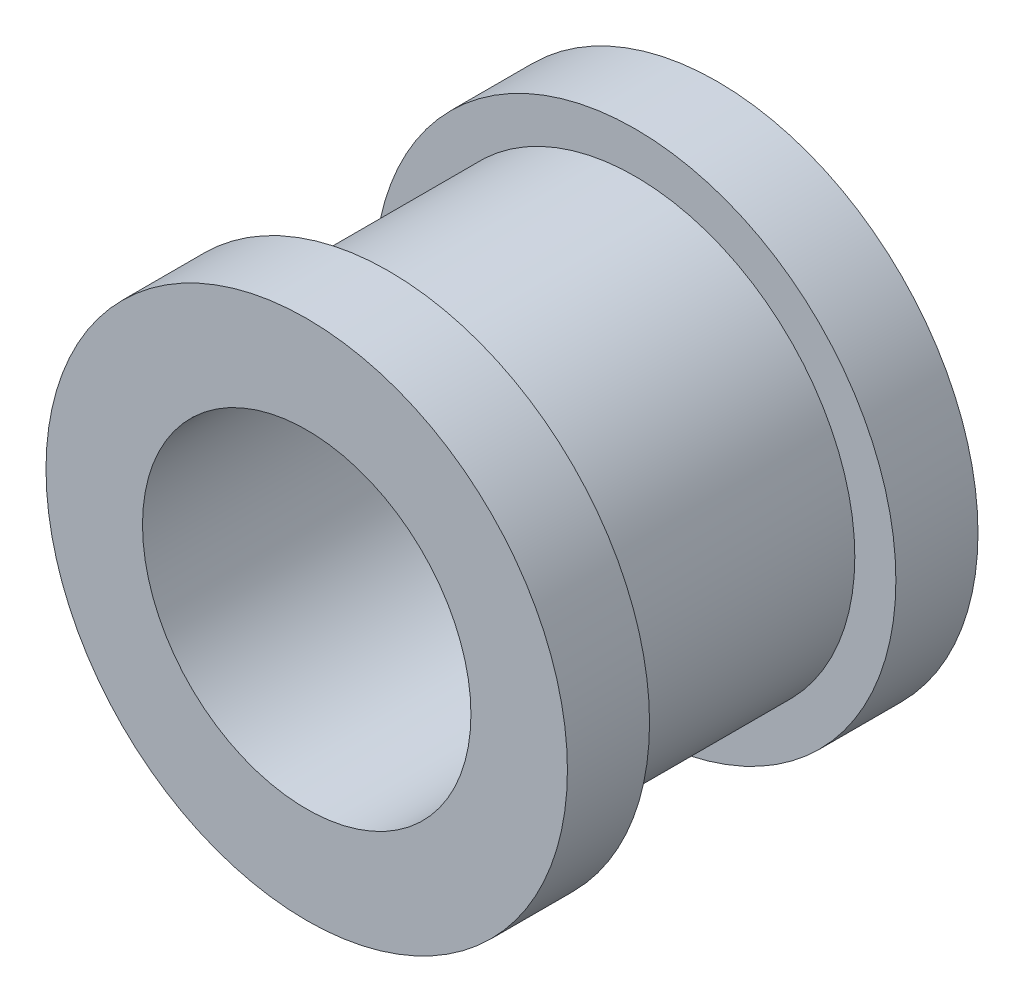
from build123d import *

# Parameters (mm, degrees)
CROQUIS1_R              = 6.35
CROQUIS1_R_2            = 4
SALIENTE_EXTRUIR1_DEPTH = 10
CROQUIS2_W              = 6
CROQUIS2_H              = 1


with BuildPart() as part:
    # Croquis1 → Saliente-Extruir1 (new body)
    with BuildSketch(Plane.XY):
        Circle(CROQUIS1_R)
        Circle(CROQUIS1_R_2, mode=Mode.SUBTRACT)
    extrude(amount=SALIENTE_EXTRUIR1_DEPTH)

    # Croquis2 → Cortar-Revolución1 (revolve, cut)
    with BuildSketch(Plane(origin=(0, 0, 0), x_dir=(0, 0, -1), z_dir=(1, 0, 0))):
        with Locations((-5, 5.85)):
            Rectangle(CROQUIS2_W, CROQUIS2_H)
    revolve(axis=Axis((0, 0, 10), (0, 0, -1)), mode=Mode.SUBTRACT)


solid = part.part
